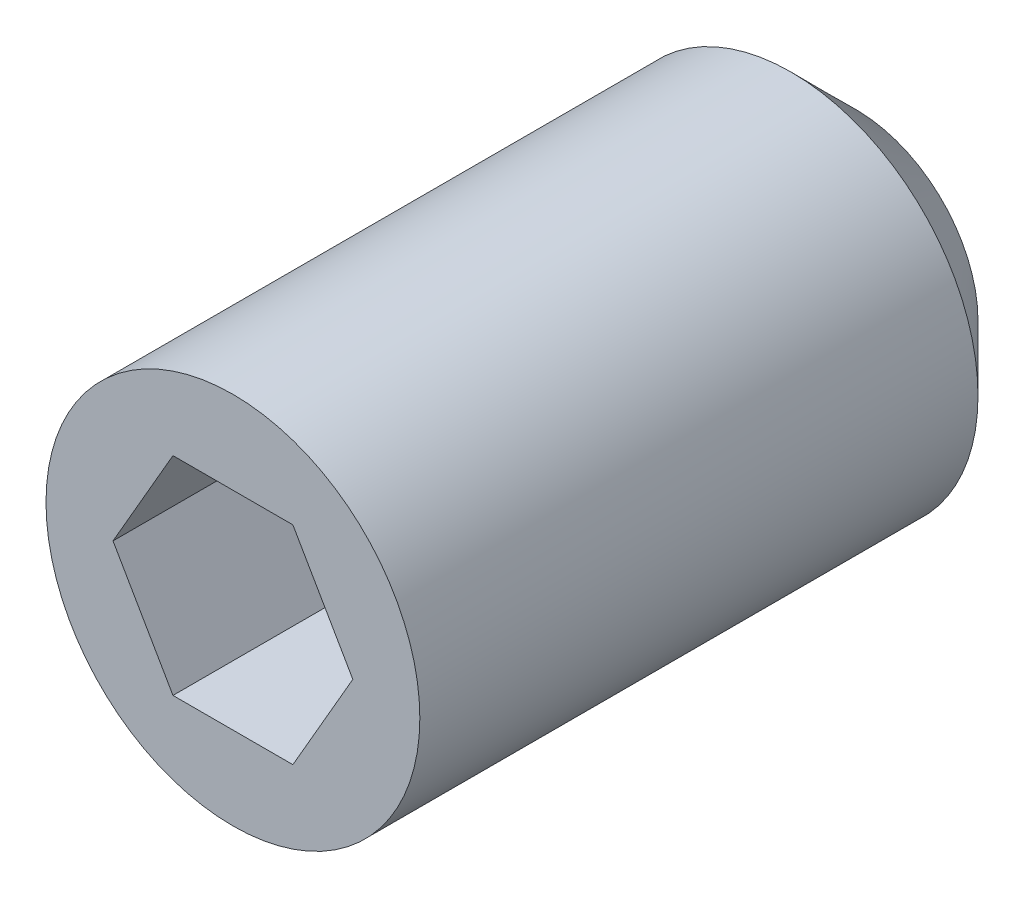
from build123d import *

# Parameters (mm, degrees)
SKETCH1_R      = 1.143
CYLINDER_DEPTH = 3.81
HEX_2_DEPTH    = 1.5875
CHAMFER1_SIZE  = 0.396875


with BuildPart() as part:
    # Sketch1 → cylinder (new body)
    with BuildSketch(Plane.XY):
        Circle(SKETCH1_R)
    extrude(amount=CYLINDER_DEPTH)

    # Hexagon - circumscribed1 → hex 2 (cut)
    with BuildSketch(Plane(origin=(0.056837481, 0.066692776, 3.81), x_dir=(1, 0, 0), z_dir=(0, 0, 1))):
        Polygon((-0.423454902, 0.568307224), (0.30977994, 0.568307224), (0.676397361, -0.066692776), (0.30977994, -0.701692776), (-0.423454902, -0.701692776), (-0.790072323, -0.066692776), align=None)
    extrude(amount=-HEX_2_DEPTH, mode=Mode.SUBTRACT)

    # Chamfer1
    chamfer1_edges = [part.edges().sort_by_distance(p)[0] for p in [
        (-1.143, 0, 0),
    ]]
    chamfer(chamfer1_edges, length=CHAMFER1_SIZE)


solid = part.part
